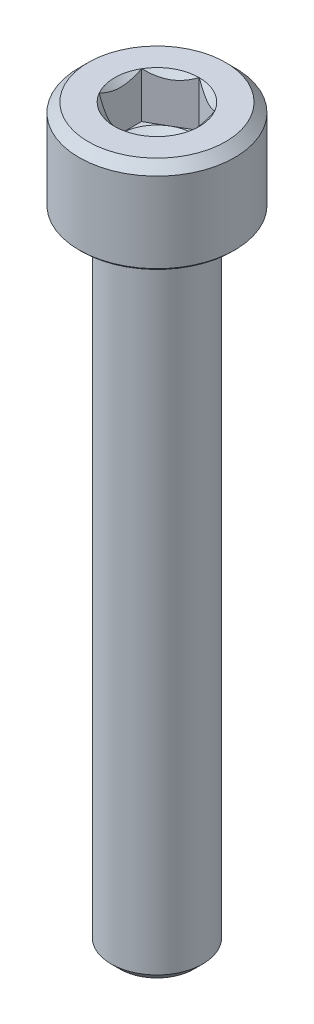
from build123d import *

# Parameters (mm, degrees)
CUT_EXTRUDE1_DEPTH = 2.5


with BuildPart() as part:
    # Sketch1 → Revolve1 (revolve)
    with BuildSketch(Plane.XY):
        Polygon((0, 1.345299462), (2, 2.5), (2, 4.690598923), (2.309401077, 5), (3.75, 5), (4.25, 4.5), (4.25, 0.125), (4.125, 0), (2.55, 0), (2.5, -0.6), (2.5, -34.5095), (2.0095, -35), (0, -35), align=None)
    revolve(axis=Axis((0, -35, 0), (0, 1, 0)))

    # Sketch2 → Cut-Extrude1 (cut)
    with BuildSketch(Plane(origin=(0, 5, 0), x_dir=(1, 0, 0), z_dir=(0, 1, 0))):
        Polygon((-2, -1.154700538), (0, -2.309401077), (2, -1.154700538), (2, 1.154700538), (0, 2.309401077), (-2, 1.154700538), align=None)
    extrude(amount=-CUT_EXTRUDE1_DEPTH, mode=Mode.SUBTRACT)


solid = part.part
